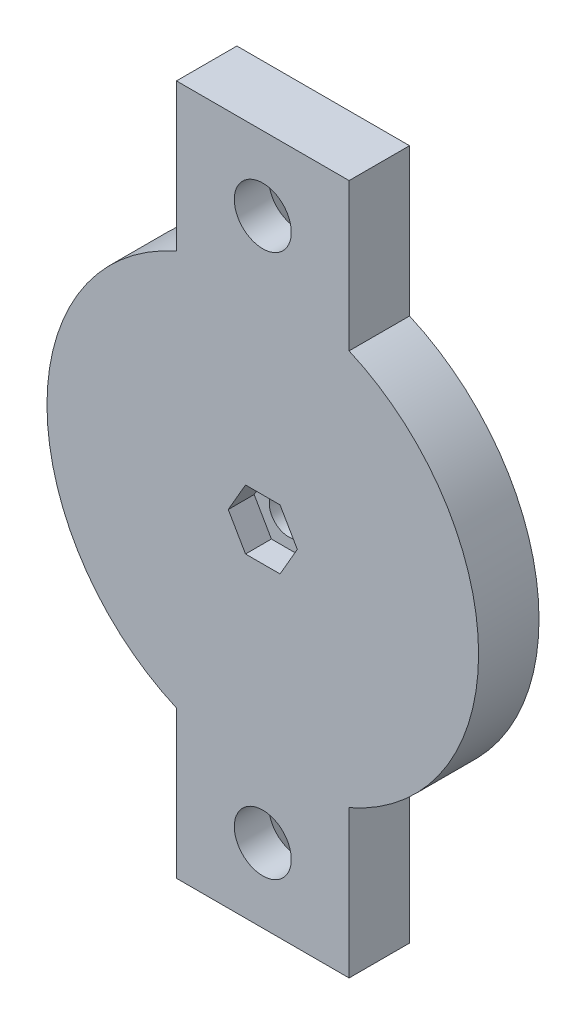
from build123d import *

# Parameters (mm, degrees)
SKETCH1_R                                           = 25
BOSS_EXTRUDE1_DEPTH                                 = 7
BOSS_EXTRUDE2_DEPTH                                 = 7
CSK_FOR_M6_COUNTERSUNK_FLAT_HEAD_SCREW2_D           = 6.6
CSK_FOR_M6_COUNTERSUNK_FLAT_HEAD_SCREW2_CSINK_D     = 12.6
CSK_FOR_M6_COUNTERSUNK_FLAT_HEAD_SCREW2_CSINK_ANGLE = 90
CUT_EXTRUDE1_DEPTH                                  = 3
M4_CLEARANCE_HOLE1_D                                = 4.5
M4_CLEARANCE_HOLE1_DEPTH                            = 10
M4_CLEARANCE_HOLE1_TIP                              = 1.351936393
CIRPATTERN1_COUNT                                   = 2


with BuildPart() as part:
    # Sketch1 → Boss-Extrude1 (new body)
    with BuildSketch(Plane.XY):
        Circle(SKETCH1_R)
    extrude(amount=BOSS_EXTRUDE1_DEPTH)

    # Sketch2 → Boss-Extrude2 (add)
    with BuildSketch(Plane.XY.offset(7)):
        with BuildLine():
            Line((-10, -40), (10, -40))
            Line((10, -40), (10, -22.912878475))
            ThreePointArc((10, -22.912878475), (0, -25), (-10, -22.912878475))
            Line((-10, -22.912878475), (-10, -40))
        make_face()
    boss_extrude2 = extrude(amount=-BOSS_EXTRUDE2_DEPTH)

    # CSK for M6 Countersunk Flat Head Screw2 (through all)
    with Locations(Plane(origin=(0, 0, 0), x_dir=(-1, 0, 0), z_dir=(0, 0, -1))):
        with Locations((0, -31.456439237)):
            csk_for_m6_countersunk_flat_head_screw2 = CounterSinkHole(CSK_FOR_M6_COUNTERSUNK_FLAT_HEAD_SCREW2_D / 2, CSK_FOR_M6_COUNTERSUNK_FLAT_HEAD_SCREW2_CSINK_D / 2, counter_sink_angle=CSK_FOR_M6_COUNTERSUNK_FLAT_HEAD_SCREW2_CSINK_ANGLE)

    # Sketch10 → Cut-Extrude1 (cut)
    with BuildSketch(Plane.XY.offset(7)):
        Polygon((4, 0), (2, 3.464101615), (-2, 3.464101615), (-4, 0), (-2, -3.464101615), (2, -3.464101615), align=None)
    extrude(amount=-CUT_EXTRUDE1_DEPTH, mode=Mode.SUBTRACT)

    # M4 Clearance Hole1
    with Locations(Plane.XY.offset(4)):
        with Locations((0, 0)):
            Hole(M4_CLEARANCE_HOLE1_D / 2, depth=M4_CLEARANCE_HOLE1_DEPTH)
            with Locations((0, 0, -(M4_CLEARANCE_HOLE1_DEPTH + M4_CLEARANCE_HOLE1_TIP / 2))):  # 118° drill point
                Cone(0, M4_CLEARANCE_HOLE1_D / 2, M4_CLEARANCE_HOLE1_TIP, mode=Mode.SUBTRACT)

    # CirPattern1: Boss-Extrude2, CSK for M6 Countersunk Flat Head Screw2 ×2 about axis
    cirpattern1_axis = Axis((0, 0, 0), (0, 0, 1))
    for i in range(1, CIRPATTERN1_COUNT):
        add(boss_extrude2.rotate(cirpattern1_axis, i * 360 / CIRPATTERN1_COUNT))
        add(csk_for_m6_countersunk_flat_head_screw2.rotate(cirpattern1_axis, i * 360 / CIRPATTERN1_COUNT), mode=Mode.SUBTRACT)


solid = part.part
